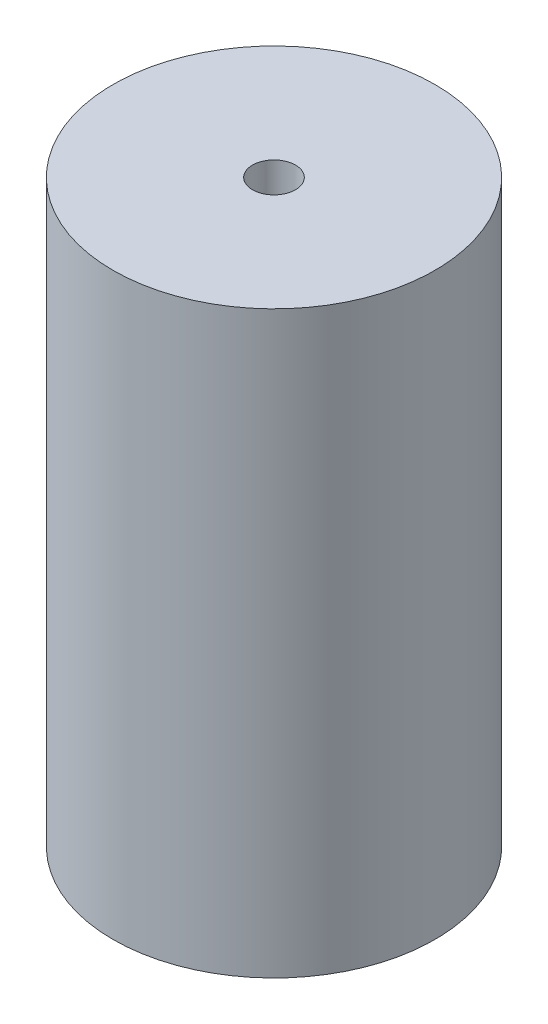
from build123d import *

# Parameters (mm, degrees)
SKETCH1_R           = 7.5
BOSS_EXTRUDE1_DEPTH = 27
SKETCH2_R           = 5
CUT_EXTRUDE1_DEPTH  = 11
SKETCH3_R           = 1
CUT_EXTRUDE2_DEPTH  = 11
SKETCH4_R           = 1.6
CUT_EXTRUDE3_DEPTH  = 11
CHAMFER1_SIZE       = 1
CHAMFER1_SIZE2      = 1.732050808


with BuildPart() as part:
    # Sketch1 → Boss-Extrude1 (new body)
    with BuildSketch(Plane(origin=(0, 0, 0), x_dir=(1, 0, 0), z_dir=(0, 1, 0))):
        Circle(SKETCH1_R)
    extrude(amount=BOSS_EXTRUDE1_DEPTH)

    # Sketch2 → Cut-Extrude1 (cut)
    with BuildSketch(Plane.XZ):
        Circle(SKETCH2_R)
    extrude(amount=-CUT_EXTRUDE1_DEPTH, mode=Mode.SUBTRACT)

    # Sketch3 → Cut-Extrude2 (cut)
    with BuildSketch(Plane(origin=(0, 27, 0), x_dir=(1, 0, 0), z_dir=(0, 1, 0))):
        Circle(SKETCH3_R)
    extrude(amount=-CUT_EXTRUDE2_DEPTH, mode=Mode.SUBTRACT)

    # Sketch4 → Cut-Extrude3 (cut)
    with BuildSketch(Plane.XY):
        with Locations((0, 22)):
            Circle(SKETCH4_R)
        with Locations((0, 5)):
            Circle(SKETCH4_R)
    extrude(amount=-CUT_EXTRUDE3_DEPTH, mode=Mode.SUBTRACT)

    # Chamfer1
    chamfer1_edges = [part.edges().sort_by_distance(p)[0] for p in [
        (-5, 0, 0),
    ]]
    chamfer1_side = [part.faces().sort_by_distance(p)[0] for p in [
        (-7.287867966, 0, 0),
    ]]
    chamfer(chamfer1_edges, length=CHAMFER1_SIZE, length2=CHAMFER1_SIZE2, reference=chamfer1_side[0])


solid = part.part
